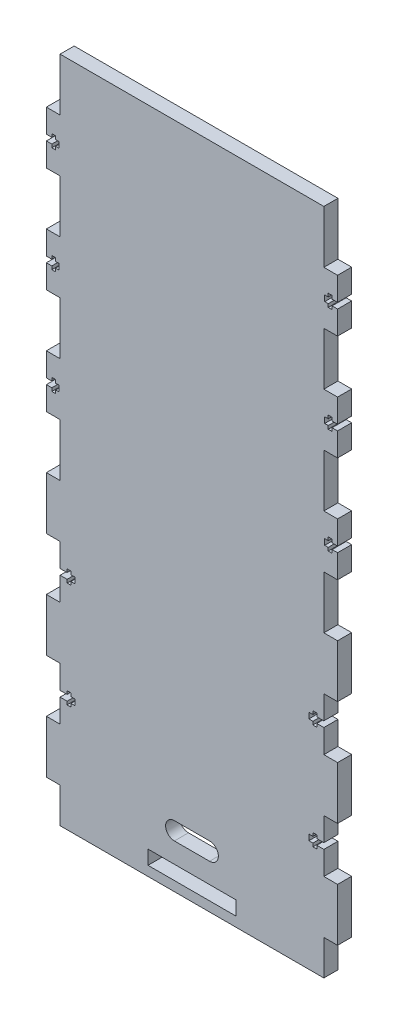
from build123d import *

# Parameters (mm, degrees)
SKETCH1_W           = 50
SKETCH1_H           = 8
BOSS_EXTRUDE1_DEPTH = 8
SKETCH2_W           = 7.8
SKETCH2_H           = 30
BOSS_EXTRUDE2_DEPTH = 8
CUT_EXTRUDE1_DEPTH  = 9


with BuildPart() as part:
    # Sketch1 → Boss-Extrude1 (new body)
    with BuildSketch(Plane.XY):
        Polygon((0, 0), (0, 380), (150, 380), (150, 0), (75, 0), align=None)
        with Locations((75, 9.5)):
            Rectangle(SKETCH1_W, SKETCH1_H, mode=Mode.SUBTRACT)
    extrude(amount=BOSS_EXTRUDE1_DEPTH)

    # Sketch2 → Boss-Extrude2 (add)
    with BuildSketch(Plane.XY.offset(8)):
        with Locations((153.9, 335)):
            Rectangle(SKETCH2_W, SKETCH2_H)
        with Locations((-3.9, 35)):
            Rectangle(SKETCH2_W, SKETCH2_H)
        with Locations((-3.9, 95)):
            Rectangle(SKETCH2_W, SKETCH2_H)
        with Locations((-3.9, 155)):
            Rectangle(SKETCH2_W, SKETCH2_H)
        with Locations((-3.9, 215)):
            Rectangle(SKETCH2_W, SKETCH2_H)
        with Locations((-3.9, 275)):
            Rectangle(SKETCH2_W, SKETCH2_H)
        with Locations((-3.9, 335)):
            Rectangle(SKETCH2_W, SKETCH2_H)
        with Locations((153.9, 275)):
            Rectangle(SKETCH2_W, SKETCH2_H)
        with Locations((153.9, 215)):
            Rectangle(SKETCH2_W, SKETCH2_H)
        with Locations((153.9, 155)):
            Rectangle(SKETCH2_W, SKETCH2_H)
        with Locations((153.9, 95)):
            Rectangle(SKETCH2_W, SKETCH2_H)
        with Locations((153.9, 35)):
            Rectangle(SKETCH2_W, SKETCH2_H)
    extrude(amount=-BOSS_EXTRUDE2_DEPTH)

    # Sketch3 → Cut-Extrude1 (cut, through all)
    with BuildSketch(Plane.XY.offset(8)):
        with BuildLine():
            Line((65, 35), (85, 35))
            ThreePointArc((85, 35), (90, 30), (85, 25))
            Line((85, 25), (65, 25))
            ThreePointArc((65, 25), (60, 30), (65, 35))
        make_face()
        Polygon((150, 123.35), (150, 126.65), (146, 126.65), (146, 128.5), (143.8, 128.5), (143.8, 126.65), (141.5, 126.65), (141.5, 123.35), (143.8, 123.35), (143.8, 121.5), (146, 121.5), (146, 123.35), align=None)
        Polygon((157.8, 333.35), (157.8, 336.65), (154.7, 336.65), (154.7, 338.5), (152.5, 338.5), (152.5, 336.65), (150.5, 336.65), (150.5, 333.35), (152.5, 333.35), (152.5, 331.5), (154.7, 331.5), (154.7, 333.35), align=None)
        Polygon((0, 63.35), (4, 63.35), (4, 61.5), (6.2, 61.5), (6.2, 63.35), (8.5, 63.35), (8.5, 66.65), (6.2, 66.65), (6.2, 68.5), (4, 68.5), (4, 66.65), (0, 66.65), align=None)
        Polygon((0, 123.35), (4, 123.35), (4, 121.5), (6.2, 121.5), (6.2, 123.35), (8.5, 123.35), (8.5, 126.65), (6.2, 126.65), (6.2, 128.5), (4, 128.5), (4, 126.65), (0, 126.65), align=None)
        Polygon((-7.8, 333.35), (-4.7, 333.35), (-4.7, 331.5), (-2.5, 331.5), (-2.5, 333.35), (-0.5, 333.35), (-0.5, 336.65), (-2.5, 336.65), (-2.5, 338.5), (-4.7, 338.5), (-4.7, 336.65), (-7.8, 336.65), align=None)
        Polygon((150, 63.35), (150, 66.65), (146, 66.65), (146, 68.5), (143.8, 68.5), (143.8, 66.65), (141.5, 66.65), (141.5, 63.35), (143.8, 63.35), (143.8, 61.5), (146, 61.5), (146, 63.35), align=None)
        Polygon((157.8, 273.35), (157.8, 276.65), (154.7, 276.65), (154.7, 278.5), (152.5, 278.5), (152.5, 276.65), (150.5, 276.65), (150.5, 273.35), (152.5, 273.35), (152.5, 271.5), (154.7, 271.5), (154.7, 273.35), align=None)
        Polygon((-7.8, 273.35), (-4.7, 273.35), (-4.7, 271.5), (-2.5, 271.5), (-2.5, 273.35), (-0.5, 273.35), (-0.5, 276.65), (-2.5, 276.65), (-2.5, 278.5), (-4.7, 278.5), (-4.7, 276.65), (-7.8, 276.65), align=None)
        Polygon((157.8, 213.35), (157.8, 216.65), (154.7, 216.65), (154.7, 218.5), (152.5, 218.5), (152.5, 216.65), (150.5, 216.65), (150.5, 213.35), (152.5, 213.35), (152.5, 211.5), (154.7, 211.5), (154.7, 213.35), align=None)
        Polygon((-7.8, 213.35), (-4.7, 213.35), (-4.7, 211.5), (-2.5, 211.5), (-2.5, 213.35), (-0.5, 213.35), (-0.5, 216.65), (-2.5, 216.65), (-2.5, 218.5), (-4.7, 218.5), (-4.7, 216.65), (-7.8, 216.65), align=None)
    extrude(amount=-CUT_EXTRUDE1_DEPTH, mode=Mode.SUBTRACT)


solid = part.part
